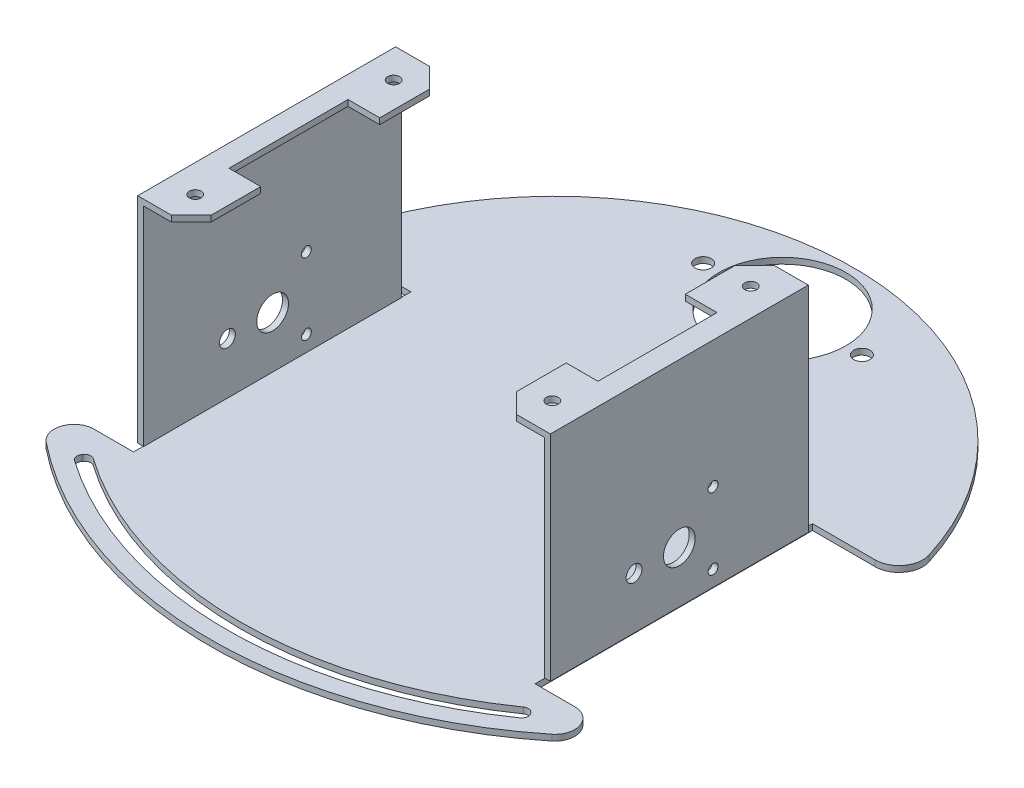
from build123d import *

# Parameters (mm, degrees)
SKETCH_1_R               = 16
EXTRUDE_1_DEPTH          = 1.5
EXTRUDE_START            = 1.5
EXTRUDE_2_DEPTH          = 53.5
SKETCH_5_R               = 4
CUT_EXTRUDE_1_DEPTH      = 54
CUT_EXTRUDE_1_DEPTH_BACK = 73.423245178
EXTRUDE_START_2          = 55.5
EXTRUDE_3_DEPTH          = 1.5
CUT_EXTRUDE_START        = 50
SKETCH_9_R               = 1.5
CUT_EXTRUDE_2_DEPTH      = 6.5
SKETCH_11_R              = 2.05
CUT_EXTRUDE_3_DEPTH      = 2.5
CHAMFER_1_SIZE           = 5
SKETCH_12_R              = 2
SKETCH_12_R_2            = 1.25
CUT_EXTRUDE_4_DEPTH      = 73.423245178
CUT_EXTRUDE_4_DEPTH_BACK = 73.423245178
CUT_EXTRUDE_5_DEPTH      = 10
FILLET_1_R               = 1.6


with BuildPart() as part:
    # Эскиз1 → Бобышка-Вытянуть1 (new body)
    with BuildSketch(Plane(origin=(0, 0, 0), x_dir=(1, 0, 0), z_dir=(0, 1, 0))):
        with BuildLine():
            Line((-50.6, 34.95), (-50.6, 0))
            Line((-50.6, 0), (-50.6, -34.95))
            Line((-50.6, -34.95), (-56.797799253, -34.95))
            Line((-56.797799253, -34.95), (-60.588262065, -34.95))
            ThreePointArc((-60.588262065, -34.95), (-65.306481849, -38.29518821), (-63.711368357, -43.854639175))
            ThreePointArc((-63.711368357, -43.854639175), (0, -66.2), (63.711368357, -43.854639175))
            ThreePointArc((63.711368357, -43.854639175), (65.306481849, -38.29518821), (60.588262065, -34.95))
            Line((60.588262065, -34.95), (50.6, -34.95))
            Line((50.6, -34.95), (50.6, 0))
            Line((50.6, 0), (50.6, 34.95))
            Line((50.6, 34.95), (66.052990091, 34.95))
            Line((66.052990091, 34.95), (66.314478057, 34.95))
            Line((66.314478057, 34.95), (66.423245178, 34.95))
            ThreePointArc((66.423245178, 34.95), (71.249879914, 37.385789411), (72.157626057, 42.715467626))
            ThreePointArc((72.157626057, 42.715467626), (0, 96), (-72.157626057, 42.715467626))
            ThreePointArc((-72.157626057, 42.715467626), (-71.249879914, 37.385789411), (-66.423245178, 34.95))
            Line((-66.423245178, 34.95), (-50.6, 34.95))
        make_face()
        with Locations((0, 78)):
            Circle(SKETCH_1_R, mode=Mode.SUBTRACT)
        with BuildLine():
            Line((-50.6, 34.95), (-50.6, 0))
            Line((-50.6, 0), (-50.6, -34.95))
            Line((-50.6, -34.95), (-56.797799253, -34.95))
            Line((-56.797799253, -34.95), (-60.588262065, -34.95))
            ThreePointArc((-60.588262065, -34.95), (-65.306481849, -38.29518821), (-63.711368357, -43.854639175))
            ThreePointArc((-63.711368357, -43.854639175), (0, -66.2), (63.711368357, -43.854639175))
            ThreePointArc((63.711368357, -43.854639175), (65.306481849, -38.29518821), (60.588262065, -34.95))
            Line((60.588262065, -34.95), (50.6, -34.95))
            Line((50.6, -34.95), (50.6, 0))
            Line((50.6, 0), (50.6, 34.95))
            Line((50.6, 34.95), (66.052990091, 34.95))
            Line((66.052990091, 34.95), (66.314478057, 34.95))
            Line((66.314478057, 34.95), (66.423245178, 34.95))
            ThreePointArc((66.423245178, 34.95), (71.249879914, 37.385789411), (72.157626057, 42.715467626))
            ThreePointArc((72.157626057, 42.715467626), (0, 96), (-72.157626057, 42.715467626))
            ThreePointArc((-72.157626057, 42.715467626), (-71.249879914, 37.385789411), (-66.423245178, 34.95))
            Line((-66.423245178, 34.95), (-50.6, 34.95))
        make_face()
        with Locations((0, 78)):
            Circle(SKETCH_1_R, mode=Mode.SUBTRACT)
        with BuildLine():
            Line((-50.6, 34.95), (-50.6, 0))
            Line((-50.6, 0), (-50.6, -34.95))
            Line((-50.6, -34.95), (-56.797799253, -34.95))
            Line((-56.797799253, -34.95), (-60.588262065, -34.95))
            ThreePointArc((-60.588262065, -34.95), (-65.306481849, -38.29518821), (-63.711368357, -43.854639175))
            ThreePointArc((-63.711368357, -43.854639175), (0, -66.2), (63.711368357, -43.854639175))
            ThreePointArc((63.711368357, -43.854639175), (65.306481849, -38.29518821), (60.588262065, -34.95))
            Line((60.588262065, -34.95), (50.6, -34.95))
            Line((50.6, -34.95), (50.6, 0))
            Line((50.6, 0), (50.6, 34.95))
            Line((50.6, 34.95), (66.052990091, 34.95))
            Line((66.052990091, 34.95), (66.314478057, 34.95))
            Line((66.314478057, 34.95), (66.423245178, 34.95))
            ThreePointArc((66.423245178, 34.95), (71.249879914, 37.385789411), (72.157626057, 42.715467626))
            ThreePointArc((72.157626057, 42.715467626), (0, 96), (-72.157626057, 42.715467626))
            ThreePointArc((-72.157626057, 42.715467626), (-71.249879914, 37.385789411), (-66.423245178, 34.95))
            Line((-66.423245178, 34.95), (-50.6, 34.95))
        make_face()
        with Locations((0, 78)):
            Circle(SKETCH_1_R, mode=Mode.SUBTRACT)
    extrude(amount=EXTRUDE_1_DEPTH)

    # Эскиз3 → Бобышка-Вытянуть2 (add)
    with BuildSketch(Plane(origin=(0, 0, 0), x_dir=(1, 0, 0), z_dir=(0, 1, 0)).offset(EXTRUDE_START)):
        Polygon((-52, 0), (-52, 32.5), (-50.5, 32.5), (-50.5, -32.5), (-52, -32.5), align=None)
        Polygon((52, -32.5), (52, 0), (52, 32.5), (50.5, 32.5), (50.5, -32.5), align=None)
    extrude(amount=EXTRUDE_2_DEPTH)

    # Эскиз5 → Вырез-Вытянуть1 (cut, two sides)
    with BuildSketch(Plane(origin=(0, 0, 0), x_dir=(0, 0, -1), z_dir=(1, 0, 0))) as cut_extrude_1_sk:
        with Locations((0, 14.5)):
            Circle(SKETCH_5_R)
    extrude(amount=CUT_EXTRUDE_1_DEPTH, mode=Mode.SUBTRACT)
    extrude(cut_extrude_1_sk.sketch, amount=-CUT_EXTRUDE_1_DEPTH_BACK, mode=Mode.SUBTRACT)

    # Эскиз6 → Бобышка-Вытянуть3 (add)
    with BuildSketch(Plane(origin=(0, 0, 0), x_dir=(1, 0, 0), z_dir=(0, 1, 0)).offset(EXTRUDE_START_2)):
        Polygon((-52, 32.5), (-52, 0), (-52, -32.5), (-38.5, -32.5), (-38.5, -15), (-46.5, -15), (-46.5, 0), (-46.5, 15), (-38.5, 15), (-38.5, 32.5), align=None)
        Polygon((46.5, 0), (46.5, -15), (38.5, -15), (38.5, -32.5), (52, -32.5), (52, 0), (52, 32.5), (38.5, 32.5), (38.5, 15), (46.5, 15), align=None)
    extrude(amount=-EXTRUDE_3_DEPTH)

    # Эскиз9 → Вырез-Вытянуть2 (cut, through all)
    with BuildSketch(Plane(origin=(0, 0, 0), x_dir=(1, 0, 0), z_dir=(0, 1, 0)).offset(CUT_EXTRUDE_START)):
        with Locations((-45, 25)):
            Circle(SKETCH_9_R)
        with Locations((-45, -25)):
            Circle(SKETCH_9_R)
        with Locations((45, -25)):
            Circle(SKETCH_9_R)
        with Locations((45, 25)):
            Circle(SKETCH_9_R)
    extrude(amount=CUT_EXTRUDE_2_DEPTH, mode=Mode.SUBTRACT)

    # Эскиз11 → Вырез-Вытянуть3 (cut, through all)
    with BuildSketch(Plane(origin=(0, 1.5, 0), x_dir=(1, 0, 0), z_dir=(0, 1, 0))):
        with Locations((20, 78)):
            Circle(SKETCH_11_R)
        with Locations((-20, 78)):
            Circle(SKETCH_11_R)
    extrude(amount=-CUT_EXTRUDE_3_DEPTH, mode=Mode.SUBTRACT)

    # Фаска1
    chamfer_1_edges = [part.edges().sort_by_distance(p)[0] for p in [
        (38.5, 54.75, -32.5),
        (38.5, 54.75, 32.5),
        (-38.5, 54.75, 32.5),
        (-38.5, 54.75, -32.5),
    ]]
    chamfer(chamfer_1_edges, length=CHAMFER_1_SIZE)

    # Эскиз12 → Вырез-Вытянуть4 (cut, two sides)
    with BuildSketch(Plane(origin=(0, 0, 0), x_dir=(0, 0, -1), z_dir=(1, 0, 0))) as cut_extrude_4_sk:
        with Locations((-11.4, 14.5)):
            Circle(SKETCH_12_R)
        with Locations((8.5, 23.5)):
            Circle(SKETCH_12_R_2)
        with Locations((8.5, 5.5)):
            Circle(SKETCH_12_R_2)
    extrude(amount=CUT_EXTRUDE_4_DEPTH, mode=Mode.SUBTRACT)
    extrude(cut_extrude_4_sk.sketch, amount=-CUT_EXTRUDE_4_DEPTH_BACK, mode=Mode.SUBTRACT)

    # Эскиз13 → Вырез-Вытянуть5 (cut)
    with BuildSketch(Plane(origin=(0, 1.5, 0), x_dir=(1, 0, 0), z_dir=(0, 1, 0))):
        with BuildLine():
            Line((0, -62), (0, -58.6))
            ThreePointArc((0, -58.6), (-29.171204269, -53.979735138), (-55.486927816, -40.571204269))
            Line((-55.486927816, -40.571204269), (-57.485397674, -43.32186205))
            ThreePointArc((-57.485397674, -43.32186205), (-30.22186205, -57.213327294), (0, -62))
        make_face()
        with BuildLine():
            ThreePointArc((55.486927816, -40.571204269), (29.171204269, -53.979735138), (0, -58.6))
            Line((0, -58.6), (0, -62))
            ThreePointArc((0, -62), (30.22186205, -57.213327294), (57.485397674, -43.32186205))
            Line((57.485397674, -43.32186205), (55.486927816, -40.571204269))
        make_face()
    extrude(amount=-CUT_EXTRUDE_5_DEPTH, mode=Mode.SUBTRACT)

    # Скругление1
    fillet_1_edges = [part.edges().sort_by_distance(p)[0] for p in [
        (-55.486927816, 0.75, 40.571204269),
        (55.486927816, 0.75, 40.571204269),
        (57.485397674, 0.75, 43.32186205),
        (-57.485397674, 0.75, 43.32186205),
    ]]
    fillet(fillet_1_edges, radius=FILLET_1_R)


solid = part.part
